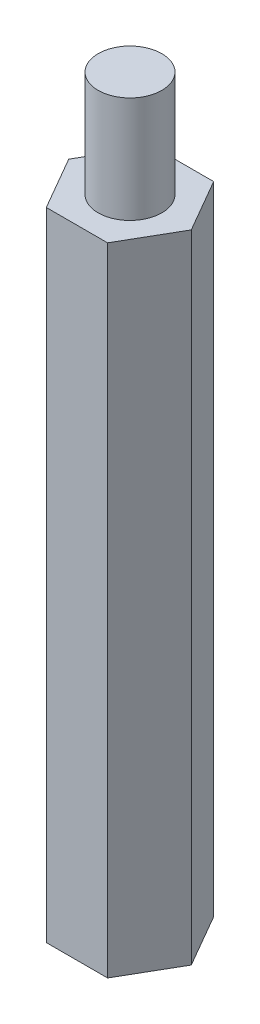
from build123d import *

# Parameters (mm, degrees)
EXTRUDE_1_DEPTH     = 30
SKETCH_2_R          = 1.5
EXTRUDE_2_DEPTH     = 5
SKETCH_3_R          = 1.5
CUT_EXTRUDE_1_DEPTH = 5


with BuildPart() as part:
    # 草圖1 → 填料-伸長1 (new body)
    with BuildSketch(Plane(origin=(0, 0, 0), x_dir=(1, 0, 0), z_dir=(0, 1, 0))):
        Polygon((2.886751346, 0), (1.443375673, 2.5), (-1.443375673, 2.5), (-2.886751346, 0), (-1.443375673, -2.5), (1.443375673, -2.5), align=None)
    extrude(amount=EXTRUDE_1_DEPTH)

    # 草圖2 → 填料-伸長2 (add)
    with BuildSketch(Plane(origin=(0, 30, 0), x_dir=(1, 0, 0), z_dir=(0, 1, 0))):
        Circle(SKETCH_2_R)
    extrude(amount=EXTRUDE_2_DEPTH)

    # 草圖3 → 除料-伸長1 (cut)
    with BuildSketch(Plane.XZ):
        Circle(SKETCH_3_R)
    extrude(amount=-CUT_EXTRUDE_1_DEPTH, mode=Mode.SUBTRACT)


solid = part.part
